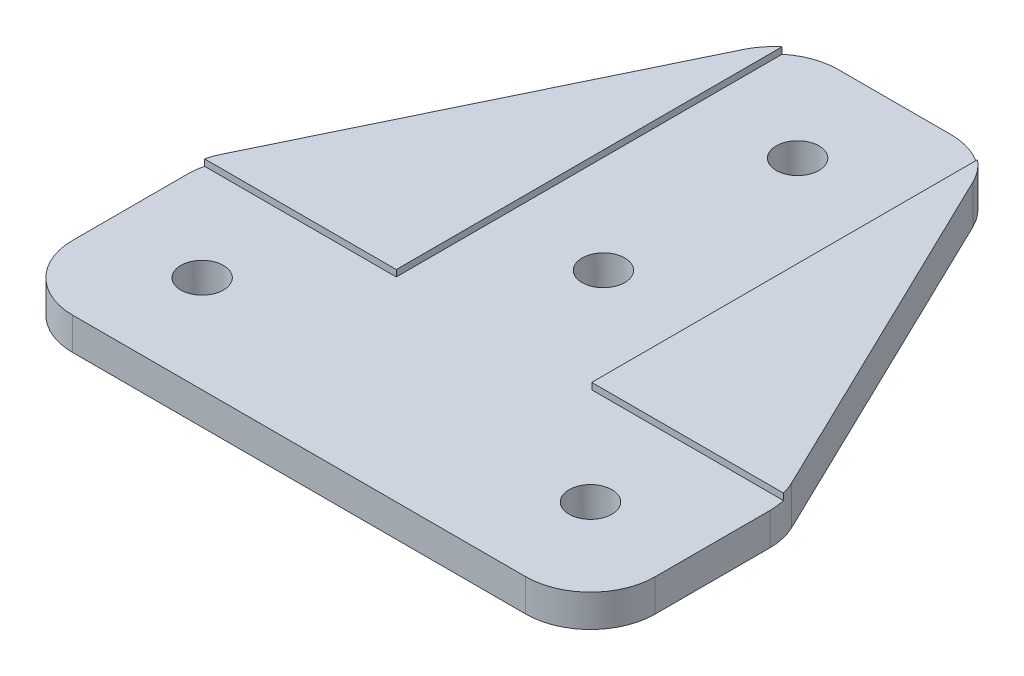
from build123d import *

# Parameters (mm, degrees)
EXTRUDE_1_DEPTH     = 3
SKETCH_2_R          = 1.65
CUT_EXTRUDE_1_DEPTH = 3
FILLET_1_R          = 5
CUT_EXTRUDE_2_DEPTH = 0.5


with BuildPart() as part:
    # ｽｹｯﾁ1 → ﾎﾞｽ - 押し出し1 (new body)
    with BuildSketch(Plane(origin=(0, 0, 0), x_dir=(1, 0, 0), z_dir=(0, 1, 0))):
        Polygon((0, 0), (45, 0), (45, 15), (30, 46), (15, 46), (0, 15), align=None)
    extrude(amount=EXTRUDE_1_DEPTH)

    # ｽｹｯﾁ2 → ｶｯﾄ - 押し出し1 (cut)
    with BuildSketch(Plane(origin=(0, 3, 0), x_dir=(1, 0, 0), z_dir=(0, 1, 0))):
        with Locations((7.5, 7.5)):
            Circle(SKETCH_2_R)
        with Locations((22.5, 38.5)):
            Circle(SKETCH_2_R)
        with Locations((22.5, 23.5)):
            Circle(SKETCH_2_R)
        with Locations((37.5, 7.5)):
            Circle(SKETCH_2_R)
    extrude(amount=-CUT_EXTRUDE_1_DEPTH, mode=Mode.SUBTRACT)

    # ﾌｨﾚｯﾄ1
    fillet_1_edges = [part.edges().sort_by_distance(p)[0] for p in [
        (0, 1.5, -15),
        (15, 1.5, -46),
        (30, 1.5, -46),
        (45, 1.5, -15),
        (45, 1.5, 0),
        (0, 1.5, 0),
    ]]
    fillet(fillet_1_edges, radius=FILLET_1_R)

    # ｽｹｯﾁ3 → ｶｯﾄ - 押し出し2 (cut)
    with BuildSketch(Plane(origin=(0, 3, 0), x_dir=(1, 0, 0), z_dir=(0, 1, 0))):
        Polygon((0, 0), (45, 0), (45, 15.05), (30.05, 15.05), (30.05, 46), (14.95, 46), (14.95, 15.05), (0, 15.05), align=None)
    extrude(amount=-CUT_EXTRUDE_2_DEPTH, mode=Mode.SUBTRACT)


solid = part.part
